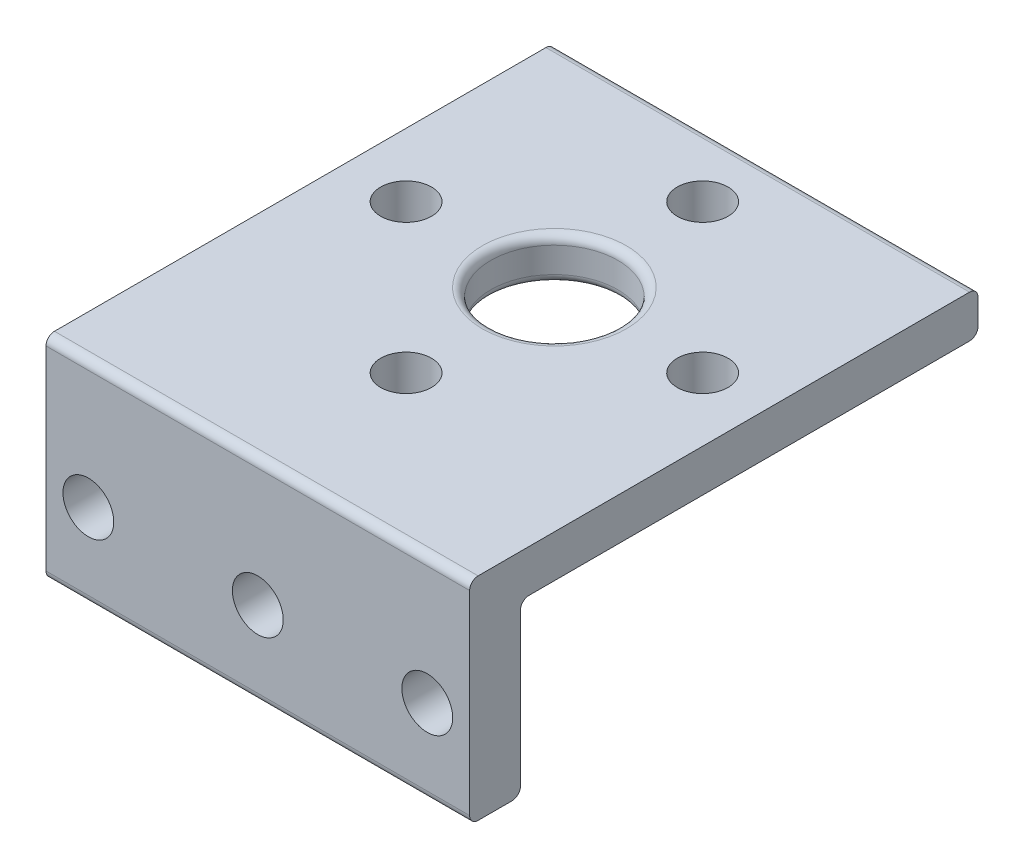
from build123d import *

# Parameters (mm, degrees)
SKETCH1_W           = 50
SKETCH1_H           = 50
SKETCH1_R           = 7.5
SKETCH1_R_2         = 3
BOSS_EXTRUDE1_DEPTH = 5
SKETCH2_W           = 50
SKETCH2_H           = 5
BOSS_EXTRUDE2_DEPTH = 10
SKETCH4_W           = 50
SKETCH4_H           = 6
BOSS_EXTRUDE3_DEPTH = 20
SKETCH5_R           = 3
CUT_EXTRUDE1_DEPTH  = 7
FILLET1_R           = 1


with BuildPart() as part:
    # Sketch1 → Boss-Extrude1 (new body)
    with BuildSketch(Plane(origin=(0, 0, 0), x_dir=(1, 0, 0), z_dir=(0, 1, 0))):
        Rectangle(SKETCH1_W, SKETCH1_H)
        Circle(SKETCH1_R, mode=Mode.SUBTRACT)
        with Locations((0, 17.5)):
            Circle(SKETCH1_R_2, mode=Mode.SUBTRACT)
        with Locations((17.5, 0)):
            Circle(SKETCH1_R_2, mode=Mode.SUBTRACT)
        with Locations((0, -17.5)):
            Circle(SKETCH1_R_2, mode=Mode.SUBTRACT)
        with Locations((-17.5, 0)):
            Circle(SKETCH1_R_2, mode=Mode.SUBTRACT)
    extrude(amount=BOSS_EXTRUDE1_DEPTH)

    # Sketch2 → Boss-Extrude2 (add)
    with BuildSketch(Plane.XY.offset(25)):
        with Locations((0, 2.5)):
            Rectangle(SKETCH2_W, SKETCH2_H)
    extrude(amount=BOSS_EXTRUDE2_DEPTH)

    # Sketch4 → Boss-Extrude3 (add)
    with BuildSketch(Plane.XZ):
        with Locations((0, 32)):
            Rectangle(SKETCH4_W, SKETCH4_H)
    extrude(amount=BOSS_EXTRUDE3_DEPTH)

    # Sketch5 → Cut-Extrude1 (cut, through all)
    with BuildSketch(Plane(origin=(0, 0, 29), x_dir=(-1, 0, 0), z_dir=(0, 0, -1))):
        with Locations((0, -10)):
            Circle(SKETCH5_R)
        with Locations((20, -10)):
            Circle(SKETCH5_R)
        with Locations((-20, -10)):
            Circle(SKETCH5_R)
    extrude(amount=-CUT_EXTRUDE1_DEPTH, mode=Mode.SUBTRACT)

    # Fillet1
    fillet1_edges = [part.edges().sort_by_distance(p)[0] for p in [
        (-7.5, 0, 0),
        (-7.5, 5, 0),
        (0, 5, 35),
        (0, 0, 29),
        (0, -20, 29),
        (0, -20, 35),
        (0, 0, -25),
        (0, 5, -25),
    ]]
    fillet(fillet1_edges, radius=FILLET1_R)


solid = part.part
